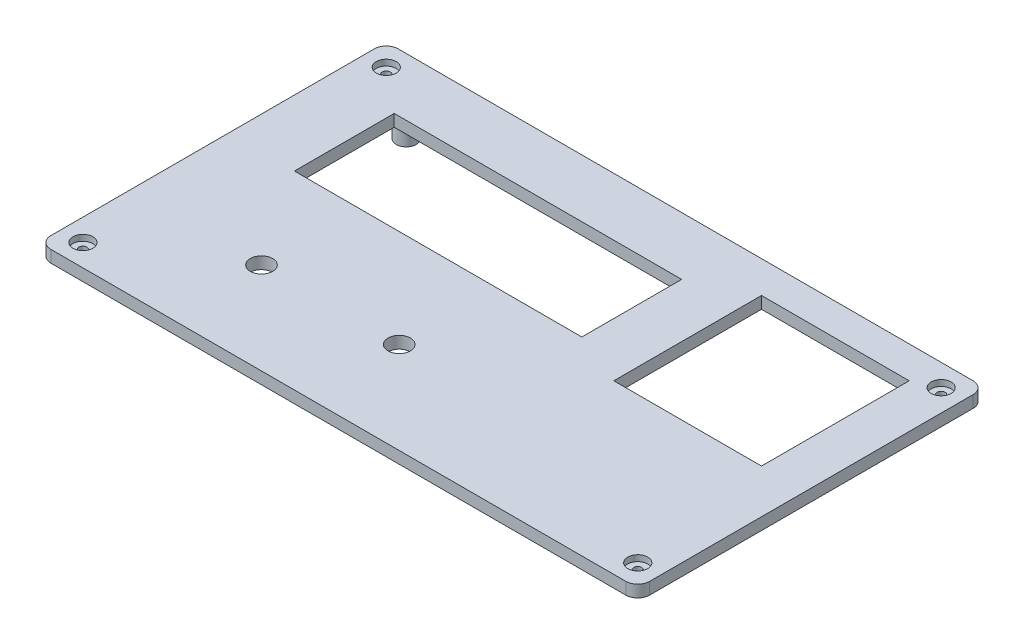
from build123d import *

# Parameters (mm, degrees)
COVER_FRAME_W                 = 150
COVER_FRAME_H                 = 87
COVER_THICKNESS_DEPTH         = 3
COVER_ITEMS_MOUTING_HOLES_R   = 2.5
COVER_ITEMS_MOUTING_HOLES_R_2 = 1
COVER_ITEMS_MOUTING_HOLES_R_3 = 1.75
COVER_ITEMS_HOLES_DEPTH       = 5
COVER_SCREW_HOLES_R           = 1
COVER_SCREW_DEPTH             = 9
COVER_EDGES_R                 = 3
SKETCH10_W                    = 37
SKETCH10_H                    = 37
LOAD_OUTLET_DEPTH             = 9
SKETCH11_R                    = 2.8
INDICATOR_LEDS_DEPTH          = 4
SKETCH12_W                    = 72
SKETCH12_H                    = 25
LCD_DEPTH                     = 4
SKETCH13_R                    = 2.5
COVER_SCREW_COUNTERSUNK_DEPTH = 1.5


with BuildPart() as part:
    # Cover_frame → cover_thickness (new body)
    with BuildSketch(Plane(origin=(0, 0, 0), x_dir=(1, 0, 0), z_dir=(0, 1, 0))):
        with Locations((75, 43.5)):
            Rectangle(COVER_FRAME_W, COVER_FRAME_H)
    extrude(amount=COVER_THICKNESS_DEPTH)

    # cover_items_mouting_holes → cover_items_holes (add)
    with BuildSketch(Plane.XZ):
        with Locations((15.5, -76.5)):
            Circle(COVER_ITEMS_MOUTING_HOLES_R)
        with Locations((15.5, -76.5)):
            Circle(COVER_ITEMS_MOUTING_HOLES_R_2, mode=Mode.SUBTRACT)
        with Locations((15.5, -45.5)):
            Circle(COVER_ITEMS_MOUTING_HOLES_R_3)
        with Locations((15.5, -45.5)):
            Circle(COVER_ITEMS_MOUTING_HOLES_R_2, mode=Mode.SUBTRACT)
        with Locations((90.5, -76.5)):
            Circle(COVER_ITEMS_MOUTING_HOLES_R)
        with Locations((90.5, -76.5)):
            Circle(COVER_ITEMS_MOUTING_HOLES_R_2, mode=Mode.SUBTRACT)
        with Locations((90.5, -45.5)):
            Circle(COVER_ITEMS_MOUTING_HOLES_R)
        with Locations((90.5, -45.5)):
            Circle(COVER_ITEMS_MOUTING_HOLES_R_2, mode=Mode.SUBTRACT)
        with Locations((15.5, -35.5)):
            Circle(COVER_ITEMS_MOUTING_HOLES_R)
        with Locations((15.5, -35.5)):
            Circle(COVER_ITEMS_MOUTING_HOLES_R_2, mode=Mode.SUBTRACT)
        with Locations((15.5, -10.5)):
            Circle(COVER_ITEMS_MOUTING_HOLES_R)
        with Locations((15.5, -10.5)):
            Circle(COVER_ITEMS_MOUTING_HOLES_R_2, mode=Mode.SUBTRACT)
        with Locations((84.5, -35.5)):
            Circle(COVER_ITEMS_MOUTING_HOLES_R)
        with Locations((84.5, -35.5)):
            Circle(COVER_ITEMS_MOUTING_HOLES_R_2, mode=Mode.SUBTRACT)
        with Locations((84.5, -10.5)):
            Circle(COVER_ITEMS_MOUTING_HOLES_R)
        with Locations((84.5, -10.5)):
            Circle(COVER_ITEMS_MOUTING_HOLES_R_2, mode=Mode.SUBTRACT)
    extrude(amount=COVER_ITEMS_HOLES_DEPTH)

    # Cover_screw_holes → cover_screw (cut, through all)
    with BuildSketch(Plane(origin=(0, 3, 0), x_dir=(1, 0, 0), z_dir=(0, 1, 0))):
        with Locations((5.5, 81.5)):
            Circle(COVER_SCREW_HOLES_R)
        with Locations((5.5, 5.5)):
            Circle(COVER_SCREW_HOLES_R)
    cover_screw = extrude(amount=-COVER_SCREW_DEPTH, mode=Mode.SUBTRACT)

    # Mirror2: cover_screw across plane
    add(cover_screw.mirror(Plane.ZY.offset(-75)), mode=Mode.SUBTRACT)

    # cover_edges
    cover_edges_edges = [part.edges().sort_by_distance(p)[0] for p in [
        (0, 1.5, -87),
        (150, 1.5, -87),
        (150, 1.5, 0),
        (0, 1.5, 0),
    ]]
    fillet(cover_edges_edges, radius=COVER_EDGES_R)

    # Sketch10 → Load_outlet (cut, through all)
    with BuildSketch(Plane(origin=(0, 3, 0), x_dir=(1, 0, 0), z_dir=(0, 1, 0))):
        with Locations((120.5, 60.5)):
            Rectangle(SKETCH10_W, SKETCH10_H)
    extrude(amount=-LOAD_OUTLET_DEPTH, mode=Mode.SUBTRACT)

    # Sketch11 → Indicator_leds (cut, through all)
    with BuildSketch(Plane.XZ):
        with Locations((67.25, -23)):
            Circle(SKETCH11_R)
        with Locations((32.75, -23)):
            Circle(SKETCH11_R)
    extrude(amount=-INDICATOR_LEDS_DEPTH, mode=Mode.SUBTRACT)

    # Sketch12 → LCD (cut, through all)
    with BuildSketch(Plane.XZ):
        with Locations((52.5, -60)):
            Rectangle(SKETCH12_W, SKETCH12_H)
    extrude(amount=-LCD_DEPTH, mode=Mode.SUBTRACT)

    # Sketch13 → cover_screw_countersunk (cut)
    with BuildSketch(Plane(origin=(0, 3, 0), x_dir=(1, 0, 0), z_dir=(0, 1, 0))):
        with Locations((5.5, 81.5)):
            Circle(SKETCH13_R)
        with Locations((5.5, 5.5)):
            Circle(SKETCH13_R)
    cover_screw_countersunk = extrude(amount=-COVER_SCREW_COUNTERSUNK_DEPTH, mode=Mode.SUBTRACT)

    # Mirror3: cover_screw_countersunk across plane
    add(cover_screw_countersunk.mirror(Plane.ZY.offset(-75)), mode=Mode.SUBTRACT)


solid = part.part
